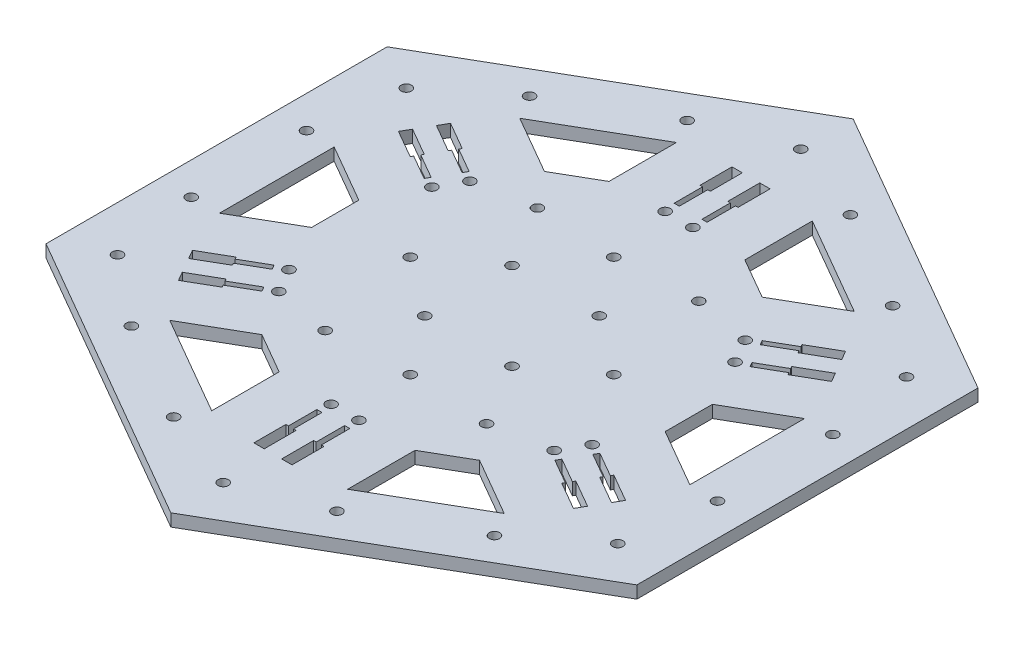
from build123d import *

# Parameters (mm, degrees)
BOSS_EXTRUDE1_DEPTH              = 4.25
CUT_EXTRUDE1_DEPTH               = 4.25
F_37_0_14015748_DIAMETER_HOLE1_D = 3.559999992
F_37_0_14015748_DIAMETER_HOLE2_D = 3.559999992
F_37_0_14015748_DIAMETER_HOLE3_D = 3.559999992
SKETCH13_R                       = 1.78
CUT_EXTRUDE7_DEPTH               = 10
F_37_0_14015748_DIAMETER_HOLE5_D = 3.559999992


with BuildPart() as part:
    # Sketch2 → Boss-Extrude1 (new body)
    with BuildSketch(Plane(origin=(0, 0, 0), x_dir=(1, 0, 0), z_dir=(0, 1, 0))):
        Polygon((0, -117.317574699), (101.6, -58.65878735), (101.6, 58.65878735), (0, 117.317574699), (-101.6, 58.65878735), (-101.6, -58.65878735), align=None)
    extrude(amount=BOSS_EXTRUDE1_DEPTH)

    # Sketch3 → Cut-Extrude1 (cut)
    with BuildSketch(Plane(origin=(0, 4.25, 0), x_dir=(1, 0, 0), z_dir=(0, 1, 0))):
        Polygon((-40.44, -70.044134658), (-30.4, -52.65434455), (-37.43503114, -48.592667427), (-57.51503114, -60.185860833), align=None)
        Polygon((-23.36496886, -56.716021673), (-30.4, -52.65434455), (-40.44, -70.044134658), (-23.36496886, -79.902408483), align=None)
        Polygon((40.44, -70.044134658), (30.4, -52.65434455), (23.36496886, -56.716021673), (23.36496886, -79.902408483), align=None)
        Polygon((37.43503114, -48.592667427), (30.4, -52.65434455), (40.44, -70.044134658), (57.51503114, -60.185860833), align=None)
        Polygon((80.88, 0), (60.8, 0), (60.8, -8.123354245), (80.88, -19.716547651), align=None)
        Polygon((60.8, 8.123354245), (60.8, 0), (80.88, 0), (80.88, 19.716547651), align=None)
        Polygon((40.44, 70.044134658), (30.4, 52.65434455), (37.43503114, 48.592667427), (57.51503114, 60.185860833), align=None)
        Polygon((23.36496886, 56.716021673), (30.4, 52.65434455), (40.44, 70.044134658), (23.36496886, 79.902408483), align=None)
        Polygon((-37.43503114, 48.592667427), (-30.4, 52.65434455), (-40.44, 70.044134658), (-57.51503114, 60.185860833), align=None)
        Polygon((-40.44, 70.044134658), (-30.4, 52.65434455), (-23.36496886, 56.716021673), (-23.36496886, 79.902408483), align=None)
        Polygon((-80.88, 19.716547651), (-60.8, 8.123354245), (-60.8, -8.123354245), (-80.88, -19.716547651), align=None)
    extrude(amount=-CUT_EXTRUDE1_DEPTH, mode=Mode.SUBTRACT)

    # #37 (0.14015748) Diameter Hole1 (through all)
    with Locations(Plane(origin=(0, 4.25, 0), x_dir=(1, 0, 0), z_dir=(0, 1, 0))):
        with Locations((62.423283757, 68.460299042), (90.5, 19.83), (90.5, -19.83), (62.423283757, -68.460299042), (28.076716243, -88.290299042), (-28.076716243, -88.290299042), (-62.423283757, -68.460299042), (-90.5, -19.83), (-90.5, 19.83), (-62.423283757, 68.460299042), (-28.076716243, 88.290299042), (28.076716243, 88.290299042)):
            Hole(F_37_0_14015748_DIAMETER_HOLE1_D / 2)

    # #37 (0.14015748) Diameter Hole2 (through all)
    with Locations(Plane(origin=(86.011542732, 4.25, -49.65878735), x_dir=(0, 0, 1), z_dir=(0, 1, 0))):
        with Locations((0, 0), (99.3175747, 0), (148.976362049, -86.011542732), (99.3175747, -172.023085464), (0, -172.023085464), (-49.658787349, -86.011542732)):
            Hole(F_37_0_14015748_DIAMETER_HOLE2_D / 2)

    # #37 (0.14015748) Diameter Hole3 (through all)
    with Locations(Plane(origin=(27.75, 4.25, -36.5), x_dir=(0, 0, 1), z_dir=(0, 1, 0))):
        with Locations((0, 0), (0, -55.5), (21.5, -42.75), (21.5, -12.75), (51.5, -12.75), (51.5, -42.75), (73, -55.5), (73, 0)):
            Hole(F_37_0_14015748_DIAMETER_HOLE3_D / 2)

    # Sketch13 → Cut-Extrude7 (cut)
    with BuildSketch(Plane(origin=(0, 4.25, 0), x_dir=(1, 0, 0), z_dir=(0, 1, 0))):
        with Locations((-47.344049213, 32.85310851)):
            Circle(SKETCH13_R)
        with Locations((-52.128291091, 24.5763547)):
            Circle(SKETCH13_R)
        with Locations((4.779601957, 57.427703591)):
            Circle(SKETCH13_R)
        with Locations((-4.780398043, 57.432601691)):
            Circle(SKETCH13_R)
        with Locations((52.123651169, 24.574595081)):
            Circle(SKETCH13_R)
        with Locations((47.347893048, 32.856246991)):
            Circle(SKETCH13_R)
        with Locations((47.344049213, -32.85310851)):
            Circle(SKETCH13_R)
        with Locations((52.128291091, -24.5763547)):
            Circle(SKETCH13_R)
        with Locations((-4.779601957, -57.427703591)):
            Circle(SKETCH13_R)
        with Locations((4.780398043, -57.432601691)):
            Circle(SKETCH13_R)
        with Locations((-52.123651169, -24.574595081)):
            Circle(SKETCH13_R)
        with Locations((-47.347893048, -32.856246991)):
            Circle(SKETCH13_R)
        Polygon((-50.363155133, 35.623863663), (-51.253150828, 34.082345901), (-59.721657924, 38.971640753), (-60.166458903, 38.201222859), (-69.692738344, 43.701222859), (-67.912941671, 46.783921124), (-58.38666223, 41.283921124), (-58.83166223, 40.513158514), align=None)
        Polygon((-55.147193685, 27.347462025), (-56.037392706, 25.80559209), (-64.505899803, 30.694886942), (-64.950700781, 29.924469048), (-74.476980223, 35.424469048), (-72.696980223, 38.507519486), (-63.170700781, 33.007519486), (-63.615700781, 32.236756876), align=None)
        Polygon((5.669593346, 61.427703591), (3.889601957, 61.427703591), (3.889601957, 71.206293295), (3, 71.206293295), (3, 82.206293295), (6.559593346, 82.206293295), (6.559593346, 71.206293295), (5.669593346, 71.206293295), align=None)
        Polygon((-3.89, 61.432601691), (-5.670398043, 61.432601691), (-5.670398043, 71.211191394), (-6.56, 71.211191394), (-6.56, 82.211191394), (-3, 82.211191394), (-3, 71.211191394), (-3.89, 71.211191394), align=None)
        Polygon((56.032748479, 25.803839929), (55.142752785, 27.345357691), (63.611259881, 32.234652542), (63.166458903, 33.005070436), (72.692738344, 38.505070436), (74.472535017, 35.422372171), (64.946255576, 29.922372171), (64.501255576, 30.693134781), align=None)
        Polygon((51.257193685, 34.085139666), (50.366994663, 35.6270096), (58.835501759, 40.516304452), (58.390700781, 41.286722346), (67.916980223, 46.786722346), (69.696980223, 43.703671908), (60.170700781, 38.203671908), (59.725700781, 38.974434518), align=None)
        Polygon((50.363155133, -35.623863663), (51.253150828, -34.082345901), (59.721657924, -38.971640753), (60.166458903, -38.201222859), (69.692738344, -43.701222859), (67.912941671, -46.783921124), (58.38666223, -41.283921124), (58.83166223, -40.513158514), align=None)
        Polygon((55.147193685, -27.347462025), (56.037392706, -25.80559209), (64.505899803, -30.694886942), (64.950700781, -29.924469048), (74.476980223, -35.424469048), (72.696980223, -38.507519486), (63.170700781, -33.007519486), (63.615700781, -32.236756876), align=None)
        Polygon((-5.669593346, -61.427703591), (-3.889601957, -61.427703591), (-3.889601957, -71.206293295), (-3, -71.206293295), (-3, -82.206293295), (-6.559593346, -82.206293295), (-6.559593346, -71.206293295), (-5.669593346, -71.206293295), align=None)
        Polygon((3.89, -61.432601691), (5.670398043, -61.432601691), (5.670398043, -71.211191394), (6.56, -71.211191394), (6.56, -82.211191394), (3, -82.211191394), (3, -71.211191394), (3.89, -71.211191394), align=None)
        Polygon((-56.032748479, -25.803839929), (-55.142752785, -27.345357691), (-63.611259881, -32.234652542), (-63.166458903, -33.005070436), (-72.692738344, -38.505070436), (-74.472535017, -35.422372171), (-64.946255576, -29.922372171), (-64.501255576, -30.693134781), align=None)
        Polygon((-51.257193685, -34.085139666), (-50.366994663, -35.6270096), (-58.835501759, -40.516304452), (-58.390700781, -41.286722346), (-67.916980223, -46.786722346), (-69.696980223, -43.703671908), (-60.170700781, -38.203671908), (-59.725700781, -38.974434518), align=None)
    extrude(amount=-CUT_EXTRUDE7_DEPTH, mode=Mode.SUBTRACT)

    # #37 (0.14015748) Diameter Hole5 (through all)
    with Locations(Plane(origin=(0, 4.25, -35), x_dir=(0, 0, 1), z_dir=(0, 1, 0))):
        with Locations((0, 0), (35, 35), (70, 0), (35, -35)):
            Hole(F_37_0_14015748_DIAMETER_HOLE5_D / 2)


solid = part.part
